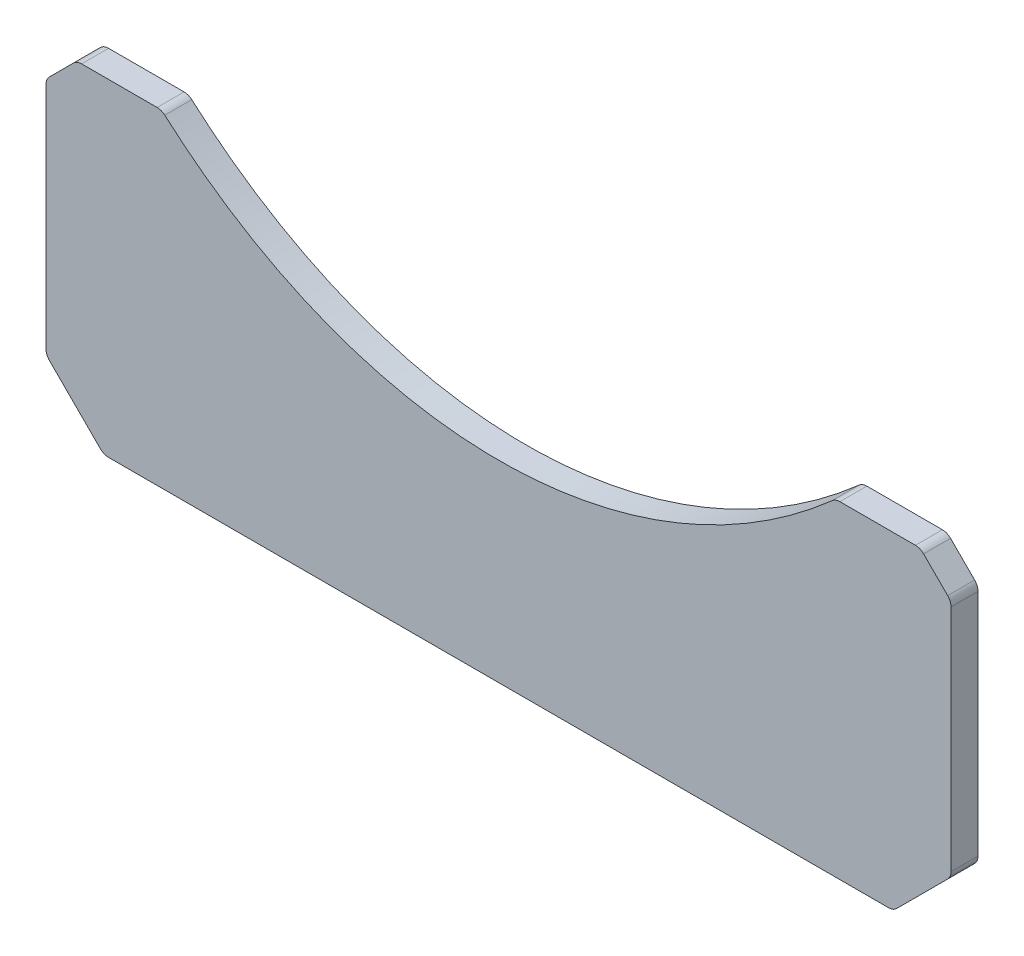
from build123d import *

# Parameters (mm, degrees)
BASE_EXTRUDE_DEPTH = 7
FILLET1_R          = 3


with BuildPart() as part:
    # Sketch1 → Base-Extrude (new body)
    with BuildSketch(Plane.XY):
        with BuildLine():
            Line((-102.5, 0), (102.5, 0))
            Line((102.5, 0), (117.5, 15))
            Line((117.5, 15), (117.5, 77))
            Line((117.5, 77), (109.5, 85))
            Line((109.5, 85), (87.5, 85))
            add(Edge.make_bspline(
                [(-87.5, 85), (0, 6.551724138), (87.5, 85)],
                knots=[2.507408813, 2.507408813, 2.507408813, 3.775776494, 3.775776494, 3.775776494], degree=2, weights=[1, 0.805555556, 1]))
            Line((-87.5, 85), (-109.5, 85))
            Line((-109.5, 85), (-117.5, 77))
            Line((-117.5, 77), (-117.5, 15))
            Line((-117.5, 15), (-102.5, 0))
        make_face()
    extrude(amount=BASE_EXTRUDE_DEPTH)

    # Fillet1
    fillet1_edges = [part.edges().sort_by_distance(p)[0] for p in [
        (102.5, 0, 3.5),
        (-102.5, 0, 3.5),
        (-117.5, 15, 3.5),
        (-117.5, 77, 3.5),
        (-109.5, 85, 3.5),
        (-87.5, 85, 3.5),
        (87.5, 85, 3.5),
        (109.5, 85, 3.5),
        (117.5, 77, 3.5),
        (117.5, 15, 3.5),
    ]]
    fillet(fillet1_edges, radius=FILLET1_R)


solid = part.part
